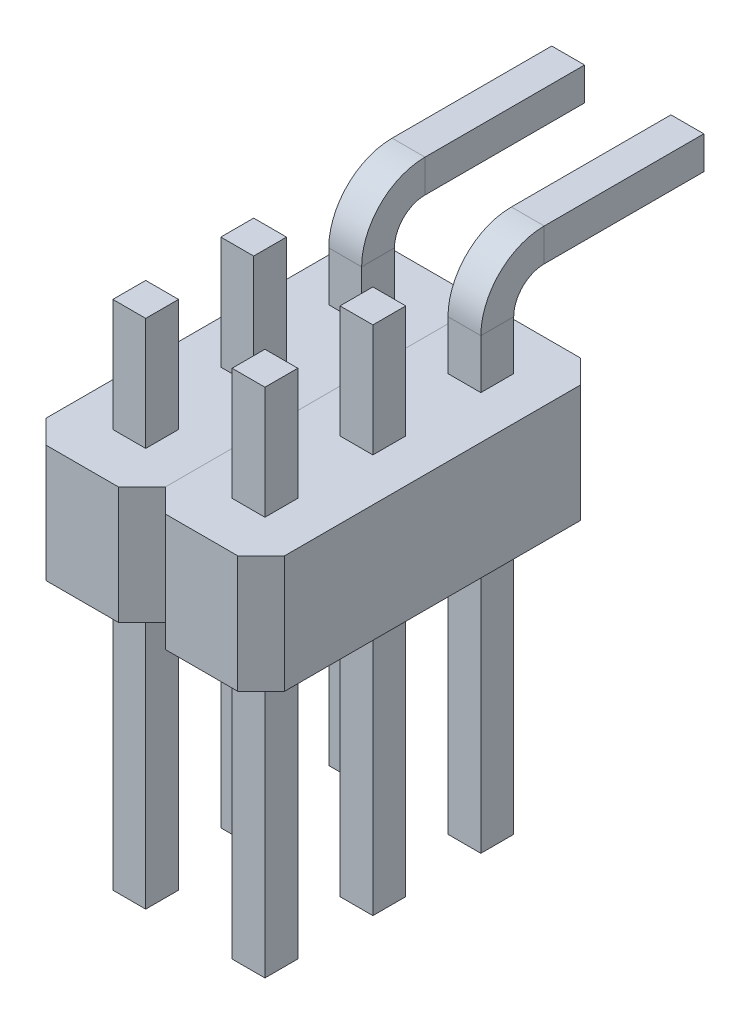
from build123d import *

# Parameters (mm, degrees)
SKETCH1_W           = 0.7
SKETCH1_H           = 0.7
SKETCH1_5_W         = 0.7
SKETCH1_5_H         = 0.7
SKETCH1_6_W         = 0.7
SKETCH1_6_H         = 0.7
SKETCH1_7_W         = 2.54
SKETCH1_7_H         = 7.3
SKETCH1_7_W_2       = 0.7
SKETCH1_7_H_2       = 0.7
BOSS_EXTRUDE1_DEPTH = 2.5
CHAMFER1_SIZE       = 0.5
LPATTERN1_COUNT     = 2
LPATTERN1_PITCH     = 2.54
SKETCH3_W           = 5.08
SKETCH3_H           = 10.35
CUT_EXTRUDE1_DEPTH  = 15.067920955


with BuildPart() as part:
    # Sweep3: sweep along a path in Sketch2
    with BuildLine(Plane(origin=(1.25, 0, 0), x_dir=(0, 0, -1), z_dir=(1, 0, 0))) as sweep3_path:
        Line((-5.95, -6), (-5.95, 8.15))
        ThreePointArc((-5.95, 8.15), (-5.657106781, 8.857106781), (-4.95, 9.15))
        Line((-4.95, 9.15), (3.05, 9.15))
    # Sketch1 → Sweep3 (sweep)
    with BuildSketch(Plane(origin=(0, 0, 0), x_dir=(1, 0, 0), z_dir=(0, 1, 0))):
        with Locations((1.27, -5.95)):
            Rectangle(SKETCH1_W, SKETCH1_H)
    sweep(path=sweep3_path.line)


with BuildPart() as body_2:
    # Sweep4: sweep along a path in Sketch2_6
    with BuildLine(Plane(origin=(1.25, 0, 0), x_dir=(0, 0, -1), z_dir=(1, 0, 0))) as sweep4_path:
        Line((-3.65, -6), (-3.65, 5.85))
        ThreePointArc((-3.65, 5.85), (-3.357106781, 6.557106781), (-2.65, 6.85))
        Line((-2.65, 6.85), (3.05, 6.85))
    # Sketch1_5 → Sweep4 (sweep)
    with BuildSketch(Plane(origin=(0, 0, 0), x_dir=(1, 0, 0), z_dir=(0, 1, 0))):
        with Locations((1.27, -3.65)):
            Rectangle(SKETCH1_5_W, SKETCH1_5_H)
    sweep(path=sweep4_path.line)


with BuildPart() as body_3:
    # Sweep5: sweep along a path in Sketch2_7
    with BuildLine(Plane(origin=(1.25, 0, 0), x_dir=(0, 0, -1), z_dir=(1, 0, 0))) as sweep5_path:
        Line((-1.35, -6), (-1.35, 3.55))
        ThreePointArc((-1.35, 3.55), (-1.057106781, 4.257106781), (-0.35, 4.55))
        Line((-0.35, 4.55), (3.05, 4.55))
    # Sketch1_6 → Sweep5 (sweep)
    with BuildSketch(Plane(origin=(0, 0, 0), x_dir=(1, 0, 0), z_dir=(0, 1, 0))):
        with Locations((1.27, -1.35)):
            Rectangle(SKETCH1_6_W, SKETCH1_6_H)
    sweep(path=sweep5_path.line)


with BuildPart() as body_4:
    # Sketch1_7 → Boss-Extrude1 (new body)
    with BuildSketch(Plane(origin=(0, 0, 0), x_dir=(1, 0, 0), z_dir=(0, 1, 0))):
        with Locations((1.27, -3.65)):
            Rectangle(SKETCH1_7_W, SKETCH1_7_H)
        with Locations((1.27, -5.95)):
            Rectangle(SKETCH1_7_W_2, SKETCH1_7_H_2, mode=Mode.SUBTRACT)
        with Locations((1.27, -3.65)):
            Rectangle(SKETCH1_7_W_2, SKETCH1_7_H_2, mode=Mode.SUBTRACT)
        with Locations((1.27, -1.35)):
            Rectangle(SKETCH1_7_W_2, SKETCH1_7_H_2, mode=Mode.SUBTRACT)
    extrude(amount=BOSS_EXTRUDE1_DEPTH)

    # Chamfer1
    chamfer1_edges = [body_4.edges().sort_by_distance(p)[0] for p in [
        (0, 1.25, 0),
        (2.54, 1.25, 0),
        (0, 1.25, 7.3),
        (2.54, 1.25, 7.3),
    ]]
    chamfer(chamfer1_edges, length=CHAMFER1_SIZE)


with BuildPart() as lpattern1_1:
    # LPattern1: pattern copy
    add(body_3.part.moved(Location(Vector(1, 0, 0) * (1 * LPATTERN1_PITCH))))


with BuildPart() as lpattern1_2:
    # LPattern1: pattern copy
    add(body_2.part.moved(Location(Vector(1, 0, 0) * (1 * LPATTERN1_PITCH))))


with BuildPart() as lpattern1_3:
    # LPattern1: pattern copy
    add(part.part.moved(Location(Vector(1, 0, 0) * (1 * LPATTERN1_PITCH))))


with BuildPart() as lpattern1_4:
    # LPattern1: pattern copy
    add(body_4.part.moved(Location(Vector(1, 0, 0) * (1 * LPATTERN1_PITCH))))


with BuildPart() as cut_extrude1_tool:
    # Sketch3 → Cut-Extrude1 (new, through all)
    with BuildSketch(Plane(origin=(0, 4.9, 0), x_dir=(1, 0, 0), z_dir=(0, 1, 0))):
        with Locations((2.54, -2.125)):
            Rectangle(SKETCH3_W, SKETCH3_H)
    extrude(amount=CUT_EXTRUDE1_DEPTH)


with BuildPart() as part_1:
    add(part.part)

    # Cut-Extrude1: cut by cut_extrude1_tool
    add(cut_extrude1_tool.part, mode=Mode.SUBTRACT)


with BuildPart() as body_2_1:
    add(body_2.part)

    # Cut-Extrude1: cut by cut_extrude1_tool
    add(cut_extrude1_tool.part, mode=Mode.SUBTRACT)


with BuildPart() as lpattern1_2_1:
    add(lpattern1_2.part)

    # Cut-Extrude1: cut by cut_extrude1_tool
    add(cut_extrude1_tool.part, mode=Mode.SUBTRACT)


with BuildPart() as lpattern1_3_1:
    add(lpattern1_3.part)

    # Cut-Extrude1: cut by cut_extrude1_tool
    add(cut_extrude1_tool.part, mode=Mode.SUBTRACT)


solid = Compound([body_3.part, body_4.part, lpattern1_1.part, lpattern1_4.part, part_1.part, body_2_1.part, lpattern1_2_1.part, lpattern1_3_1.part])
